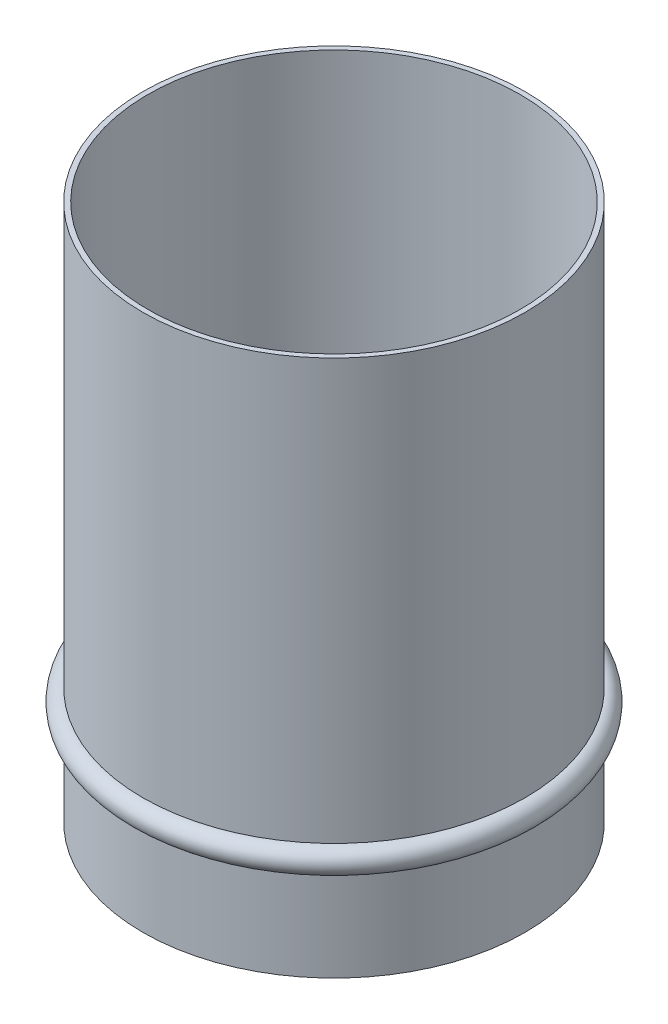
from build123d import *


with BuildPart() as part:
    # Sketch1 → Revolve1 (revolve)
    with BuildSketch(Plane.XY):
        with BuildLine():
            Line((-177.8, 254), (-182.5625, 254))
            Line((-182.5625, 254), (-182.5625, -147.412175031))
            ThreePointArc((-182.5625, -147.412175031), (-194.471779803, -159.321454834), (-182.5625, -171.230734636))
            Line((-182.5625, -171.230734636), (-182.5625, -258.7625))
            Line((-182.5625, -258.7625), (0, -258.7625))
            Line((0, -258.7625), (0, -254))
            Line((0, -254), (-177.8, -254))
            Line((-177.8, -254), (-177.8, 254))
        make_face()
    revolve(axis=Axis((0, -254, 0), (0, 1, 0)))


solid = part.part
